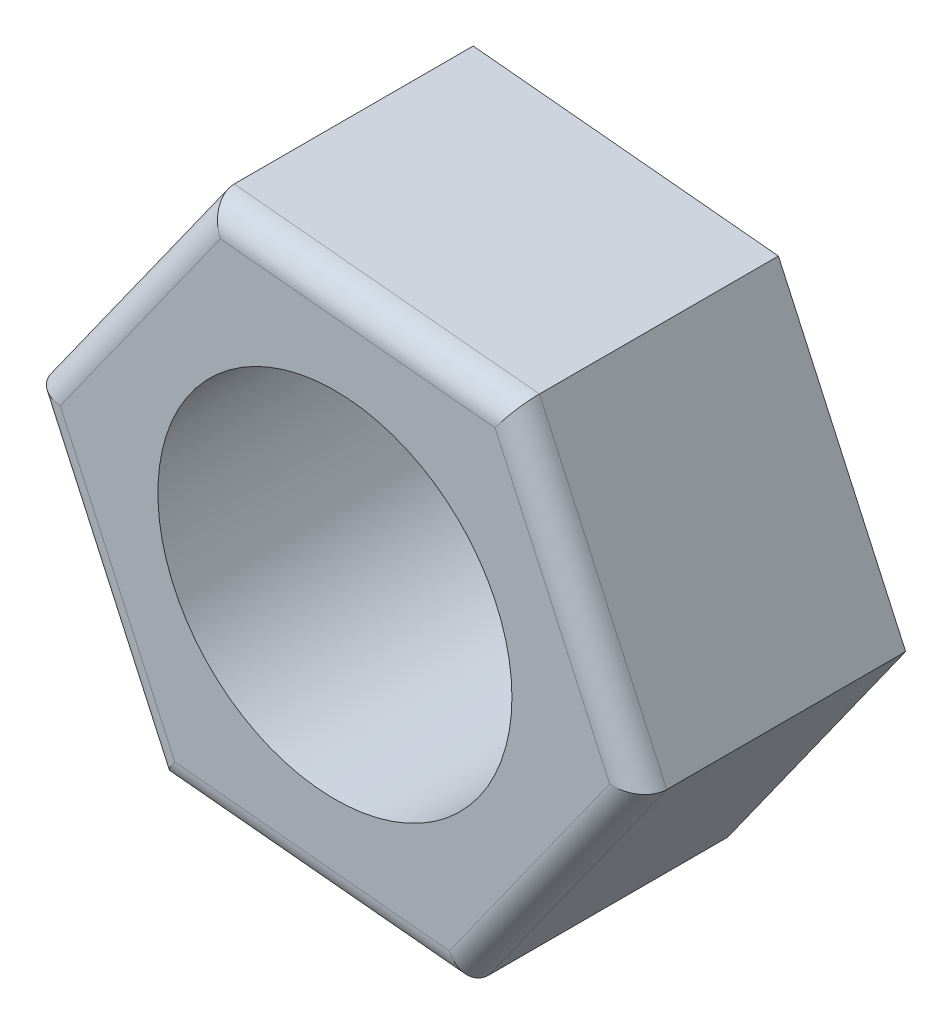
from build123d import *

# Parameters (mm, degrees)
SKETCH_1_R      = 2
EXTRUDE_1_DEPTH = 3
FILLET_1_R      = 0.3


with BuildPart() as part:
    # 草图1 → 凸台-拉伸1 (new body)
    with BuildSketch(Plane.XY):
        Polygon((1.437729481, -3.151655746), (3.44827868, -0.330717618), (2.010549199, 2.820938127), (-1.437729481, 3.151655746), (-3.44827868, 0.330717618), (-2.010549199, -2.820938127), align=None)
        Circle(SKETCH_1_R, mode=Mode.SUBTRACT)
    extrude(amount=EXTRUDE_1_DEPTH)

    # 圆角1
    fillet_1_edges = [part.edges().sort_by_distance(p)[0] for p in [
        (2.72941394, 1.245110255, 3),
        (0.286409859, 2.986296936, 3),
        (-2.443004081, 1.741186682, 3),
        (-2.72941394, -1.245110255, 3),
        (-0.286409859, -2.986296936, 3),
        (2.443004081, -1.741186682, 3),
    ]]
    fillet(fillet_1_edges, radius=FILLET_1_R)


solid = part.part
